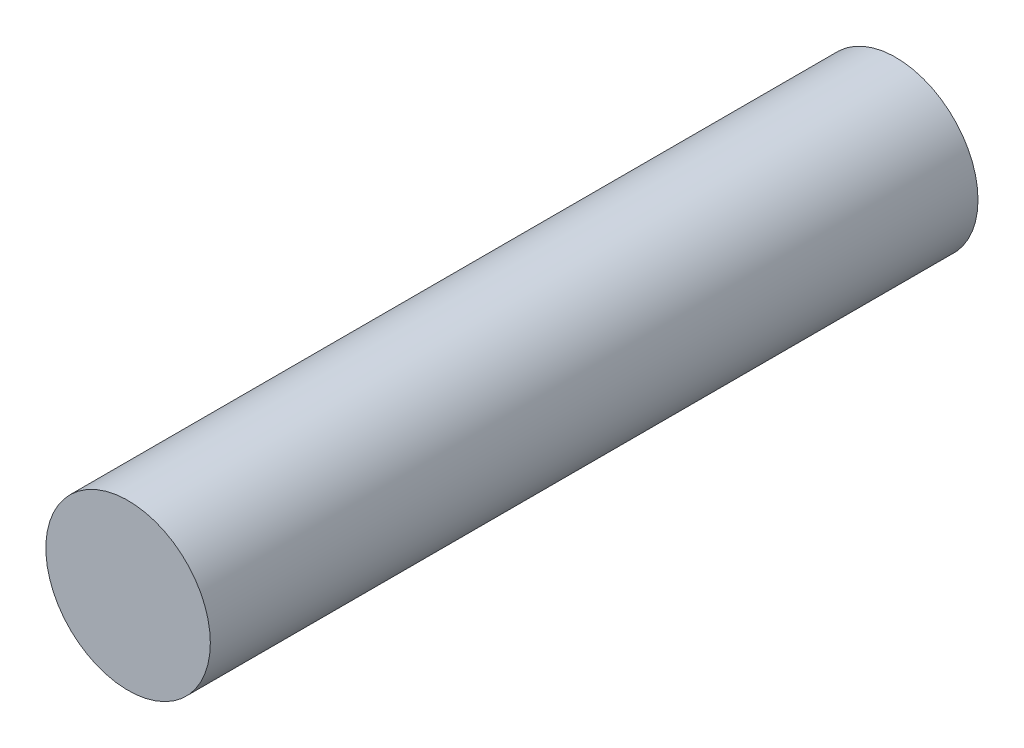
from build123d import *

# Parameters (mm, degrees)
SKETCH1_R           = 6
BOSS_EXTRUDE1_DEPTH = 28


with BuildPart() as part:
    # Sketch1 → Boss-Extrude1 (new body, symmetric)
    with BuildSketch(Plane.XY):
        Circle(SKETCH1_R)
    extrude(amount=BOSS_EXTRUDE1_DEPTH, both=True)


solid = part.part
